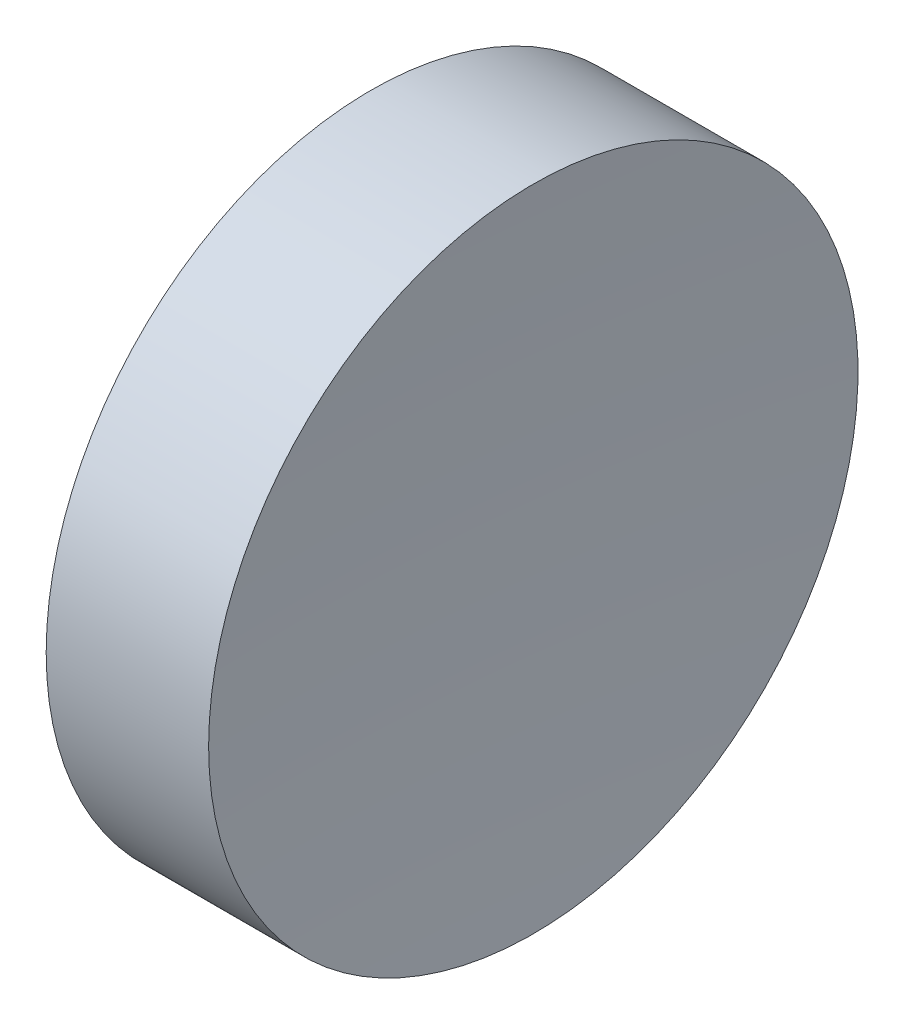
from build123d import *


with BuildPart() as part:
    # 草图1 → 旋转1 (revolve)
    with BuildSketch(Plane(origin=(0, 0, 0), x_dir=(1, 0, 0), z_dir=(0, 1, 0)), mode=Mode.PRIVATE) as revolve_1_sk:
        with BuildLine():
            Line((0, 0), (5.95, 0))
            ThreePointArc((5.95, 0), (6.050933543, 6.353206258), (6.353632298, 12.7))
            Line((6.353632298, 12.7), (0, 12.7))
            Line((0, 12.7), (0, 0))
        make_face()
    revolve(revolve_1_sk.sketch.rotate(Axis((0, 0, 0), (1, 0, 0)), 180), axis=Axis((0, 0, 0), (1, 0, 0)))  # turned: the seam where the file's is


solid = part.part
